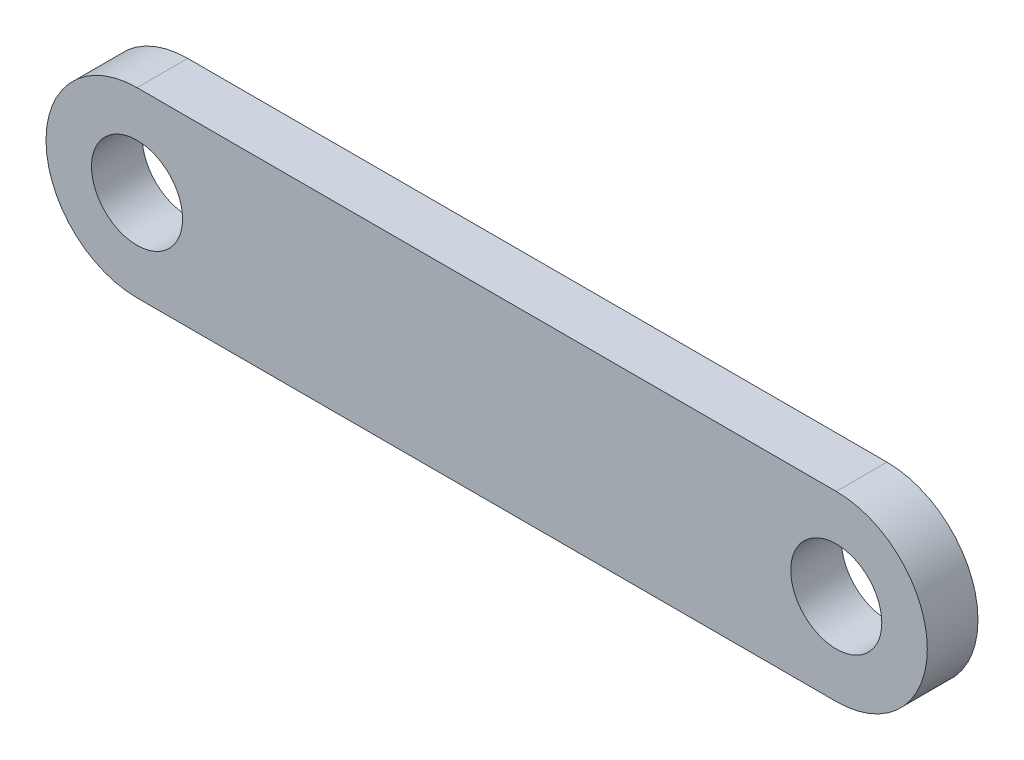
from build123d import *

# Parameters (mm, degrees)
SKETCH1_R           = 4.49
BOSS_EXTRUDE1_DEPTH = 5


with BuildPart() as part:
    # Sketch1 → Boss-Extrude1 (new body)
    with BuildSketch(Plane.XY):
        with BuildLine():
            ThreePointArc((-34.49, 8.98), (-43.47, 0), (-34.49, -8.98))
            Line((-34.49, -8.98), (34.49, -8.98))
            ThreePointArc((34.49, -8.98), (43.47, 0), (34.49, 8.98))
            Line((34.49, 8.98), (-34.49, 8.98))
        make_face()
        with Locations((-34.49, 0)):
            Circle(SKETCH1_R, mode=Mode.SUBTRACT)
        with Locations((34.49, 0)):
            Circle(SKETCH1_R, mode=Mode.SUBTRACT)
    extrude(amount=BOSS_EXTRUDE1_DEPTH)


solid = part.part
